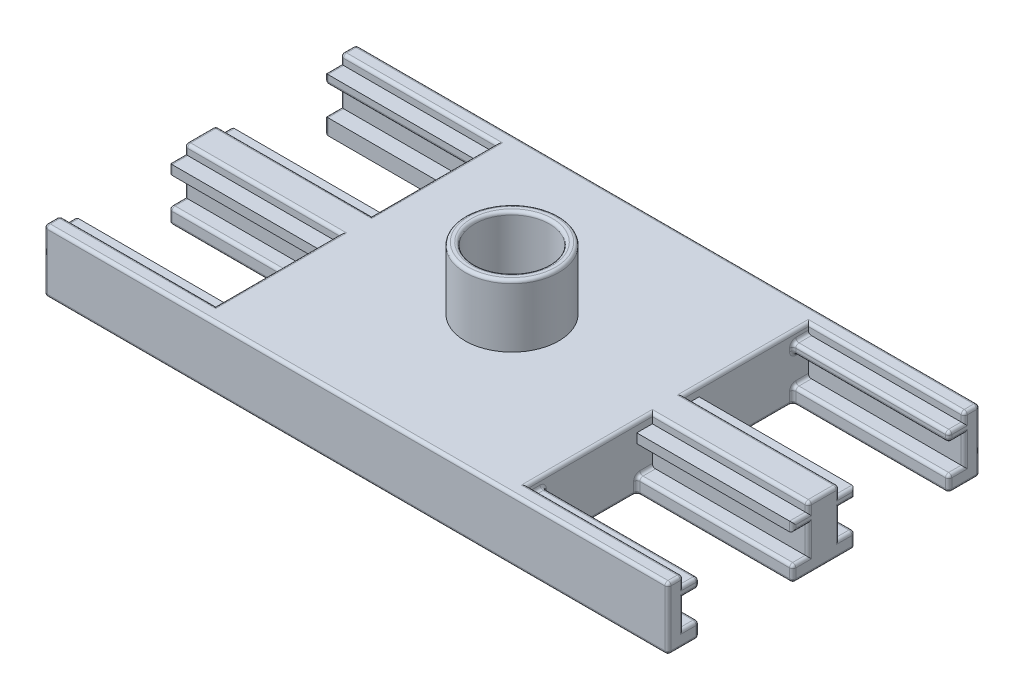
from build123d import *

# Parameters (mm, degrees)
SKETCH1_W           = 1000
SKETCH1_H           = 1000
BOSS_EXTRUDE1_DEPTH = 200
BOSS_EXTRUDE2_DEPTH = 500
FILLET1_R           = 10
SKETCH3_R           = 150
SKETCH3_R_2         = 120
BOSS_EXTRUDE3_DEPTH = 200
FILLET3_R           = 10


with BuildPart() as part:
    # Sketch1 → Boss-Extrude1 (new body)
    with BuildSketch(Plane(origin=(0, 0, 0), x_dir=(1, 0, 0), z_dir=(0, 1, 0))):
        Rectangle(SKETCH1_W, SKETCH1_H)
    extrude(amount=BOSS_EXTRUDE1_DEPTH)

    # Sketch2 → Boss-Extrude2 (add)
    with BuildSketch(Plane(origin=(500, 0, 0), x_dir=(0, 0, -1), z_dir=(1, 0, 0))):
        Polygon((-500, 200), (-500, 0), (-400, 0), (-400, 50), (-450, 50), (-450, 140), (-400, 140), (-400, 170), (-450, 170), (-450, 200), align=None)
        Polygon((-100, 0), (100, 0), (100, 50), (50, 50), (50, 140), (100, 140), (100, 170), (50, 170), (50, 200), (-50, 200), (-50, 170), (-100, 170), (-100, 140), (-50, 140), (-50, 50), (-100, 50), align=None)
        Polygon((400, 140), (450, 140), (450, 50), (400, 50), (400, 0), (500, 0), (500, 200), (450, 200), (450, 170), (400, 170), align=None)
    boss_extrude2 = extrude(amount=BOSS_EXTRUDE2_DEPTH)

    # Mirror9: Boss-Extrude2 across plane
    add(boss_extrude2.mirror(Plane(origin=(0, 0, 0), x_dir=(0, 0, 1), z_dir=(1, 0, 0))))

    # Fillet1
    fillet1_edges = [part.edges().sort_by_distance(p)[0] for p in [
        (-500, 50, 425),
        (-500, 25, 400),
        (-750, 50, 400),
        (-1000, 0, 450),
        (-750, 0, 400),
        (-1000, 100, 500),
        (-1000, 200, 475),
        (-750, 200, 450),
        (-1000, 95, 450),
        (-1000, 50, 425),
        (-1000, 25, 400),
        (-1000, 185, 450),
        (-1000, 170, 425),
        (-1000, 155, 400),
        (-1000, 140, 425),
        (0, 200, -500),
        (500, 0, 250),
        (-500, 0, 250),
        (-500, 200, 250),
        (500, 200, 250),
        (-1000, 200, 0),
        (-750, 200, 50),
        (-750, 200, -50),
        (-1000, 50, -75),
        (-1000, 25, -100),
        (-750, 50, -100),
        (-1000, 0, 0),
        (-750, 0, -100),
        (-1000, 25, 100),
        (-750, 0, 100),
        (-1000, 50, 75),
        (-750, 50, 100),
        (-1000, 95, 50),
        (-1000, 140, 75),
        (-1000, 155, 100),
        (-1000, 170, 75),
        (-1000, 185, 50),
        (-1000, 185, -50),
        (-1000, 170, -75),
        (-1000, 155, -100),
        (-1000, 140, -75),
        (-1000, 95, -50),
        (-500, 50, 75),
        (-500, 25, 100),
        (-500, 25, -100),
        (-500, 50, -75),
        (1000, 95, 450),
        (1000, 140, 425),
        (1000, 155, 400),
        (750, 140, 400),
        (1000, 170, 425),
        (-500, 0, -250),
        (-500, 200, -250),
        (750, 170, 400),
        (-1000, 95, -450),
        (1000, 185, 450),
        (-1000, 140, -425),
        (-750, 140, -450),
        (-1000, 155, -400),
        (-750, 140, -400),
        (-1000, 170, -425),
        (-1000, 185, -450),
        (-1000, 200, -475),
        (-750, 200, -450),
        (-1000, 100, -500),
        (-1000, 0, -450),
        (-1000, 25, -400),
        (-1000, 50, -425),
        (-500, 155, -400),
        (-500, 140, -425),
        (750, 200, 450),
        (1000, 25, 400),
        (750, 0, 400),
        (1000, 50, 425),
        (750, 50, 400),
        (1000, 200, 475),
        (1000, 100, 500),
        (1000, 0, 450),
        (500, 50, 425),
        (500, 25, 400),
        (500, 170, 425),
        (500, 155, 400),
        (500, 140, 425),
        (500, 0, -250),
        (500, 200, -250),
        (0, 0, -500),
        (750, 200, -50),
        (750, 200, 50),
        (500, 50, 75),
        (500, 25, 100),
        (750, 50, 100),
        (750, 0, 100),
        (500, 25, -100),
        (750, 0, -100),
        (500, 50, -75),
        (750, 50, -100),
        (1000, 95, -50),
        (1000, 140, -75),
        (1000, 155, -100),
        (1000, 170, -75),
        (1000, 185, -50),
        (0, 0, 500),
        (1000, 200, 0),
        (1000, 185, 50),
        (1000, 170, 75),
        (1000, 155, 100),
        (1000, 140, 75),
        (1000, 95, 50),
        (1000, 50, 75),
        (1000, 25, 100),
        (1000, 0, 0),
        (1000, 25, -100),
        (1000, 50, -75),
        (0, 200, 500),
        (500, 50, -425),
        (500, 25, -400),
        (750, 50, -400),
        (750, 0, -400),
        (750, 200, -450),
        (500, 170, -425),
        (500, 155, -400),
        (750, 170, -400),
        (500, 140, -425),
        (750, 140, -400),
        (1000, 95, -450),
        (1000, 50, -425),
        (1000, 25, -400),
        (1000, 0, -450),
        (1000, 100, -500),
        (1000, 200, -475),
        (1000, 185, -450),
        (1000, 170, -425),
        (1000, 155, -400),
        (1000, 140, -425),
    ]]
    fillet(fillet1_edges, radius=FILLET1_R)

    # Sketch3 → Boss-Extrude3 (add)
    with BuildSketch(Plane(origin=(0, 200, 0), x_dir=(1, 0, 0), z_dir=(0, 1, 0))):
        Circle(SKETCH3_R)
        Circle(SKETCH3_R_2, mode=Mode.SUBTRACT)
    extrude(amount=BOSS_EXTRUDE3_DEPTH)

    # Fillet3
    fillet3_edges = [part.edges().sort_by_distance(p)[0] for p in [
        (-150, 400, 0),
        (-120, 400, 0),
    ]]
    fillet(fillet3_edges, radius=FILLET3_R)


solid = part.part
